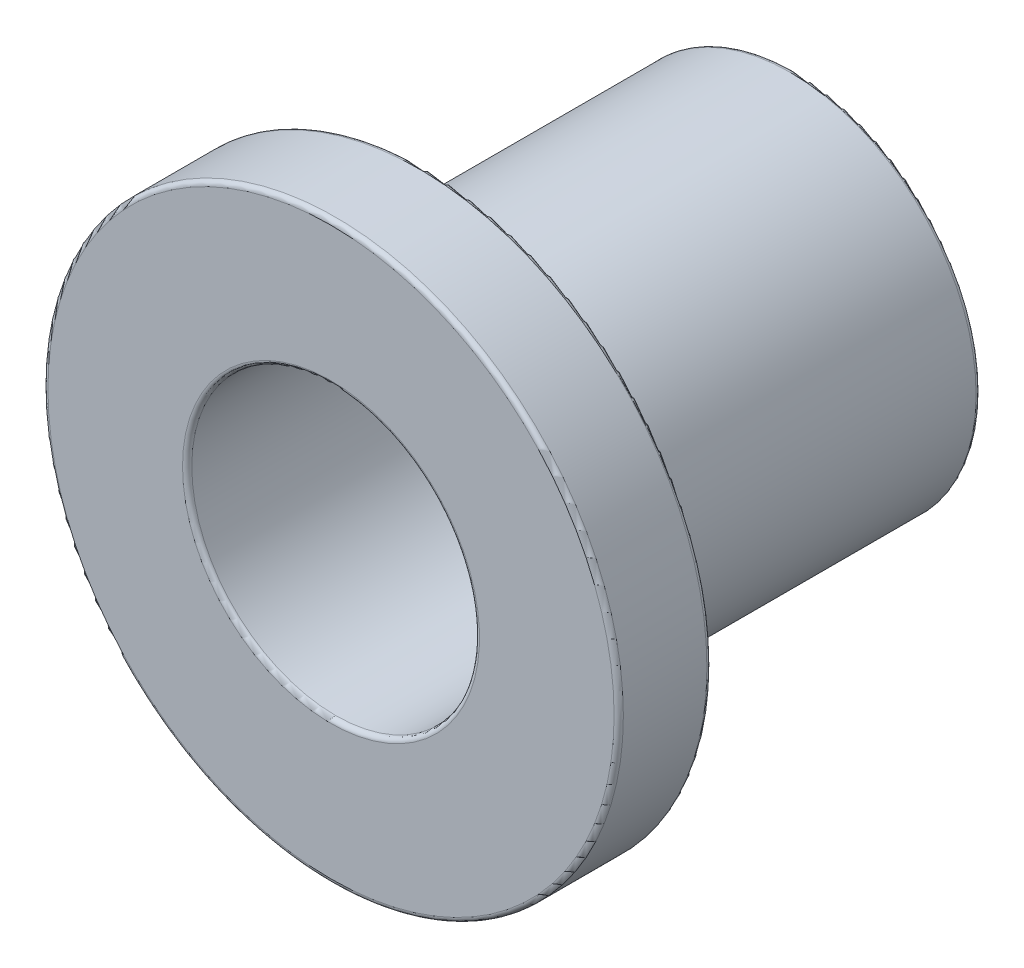
from build123d import *

# Parameters (mm, degrees)
FILLET1_R = 0.05


with BuildPart() as part:
    # Sketch2 → Revolve1 (revolve)
    with BuildSketch(Plane(origin=(0, 0, 0), x_dir=(0, 0, -1), z_dir=(1, 0, 0))):
        Polygon((-2.5, 1.55), (2.5, 1.55), (2.5, 2), (-1.5, 2), (-1.5, 3.1), (-2.5, 3.1), align=None)
    revolve(axis=Axis((0, 0, 2.5), (0, 0, -1)))

    # Fillet1
    fillet1_edges = [part.edges().sort_by_distance(p)[0] for p in [
        (0, -3.1, 2.5),
        (0, -3.1, 1.5),
        (0, -2, 1.5),
        (0, -2, -2.5),
        (0, -1.55, -2.5),
        (0, -1.55, 2.5),
    ]]
    fillet(fillet1_edges, radius=FILLET1_R)


solid = part.part
